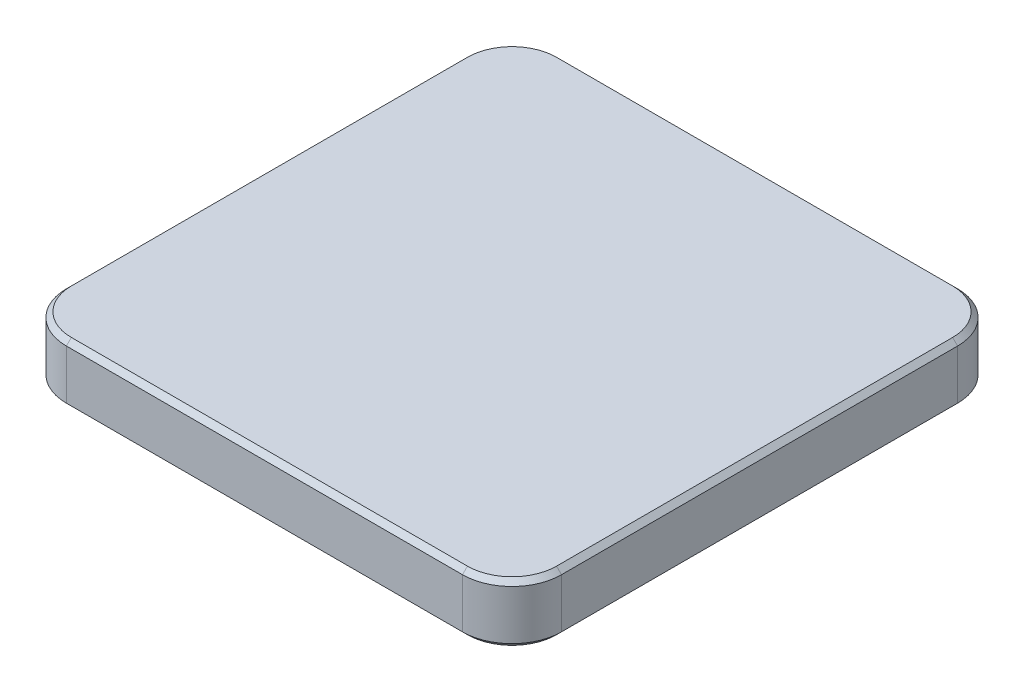
from build123d import *

# Parameters (mm, degrees)
SALIENTE_EXTRUIR1_DEPTH = 12
CHAFL_N1_SIZE           = 1


with BuildPart() as part:
    # Croquis2 → Saliente-Extruir1 (new body)
    with BuildSketch(Plane(origin=(0, 0, 0), x_dir=(1, 0, 0), z_dir=(0, 1, 0))):
        with BuildLine():
            Line((-40, -50), (40, -50))
            ThreePointArc((40, -50), (47.071067812, -47.071067812), (50, -40))
            Line((50, -40), (50, 40))
            ThreePointArc((50, 40), (47.071067812, 47.071067812), (40, 50))
            Line((40, 50), (-40, 50))
            ThreePointArc((-40, 50), (-47.071067812, 47.071067812), (-50, 40))
            Line((-50, 40), (-50, -40))
            ThreePointArc((-50, -40), (-47.071067812, -47.071067812), (-40, -50))
        make_face()
    extrude(amount=SALIENTE_EXTRUIR1_DEPTH)

    # Chaflán1
    chafl_n1_edges = [part.edges().sort_by_distance(p)[0] for p in [
        (50, 0, 0),
        (47.071067812, 0, 47.071067812),
        (0, 0, 50),
        (-47.071067812, 0, 47.071067812),
        (47.071067812, 12, 47.071067812),
        (50, 12, 0),
        (47.071067812, 12, -47.071067812),
        (0, 12, -50),
        (-47.071067812, 12, -47.071067812),
        (-50, 12, 0),
        (-47.071067812, 12, 47.071067812),
        (-50, 0, 0),
        (0, 12, 50),
        (-47.071067812, 0, -47.071067812),
        (0, 0, -50),
        (47.071067812, 0, -47.071067812),
    ]]
    chamfer(chafl_n1_edges, length=CHAFL_N1_SIZE)


solid = part.part
